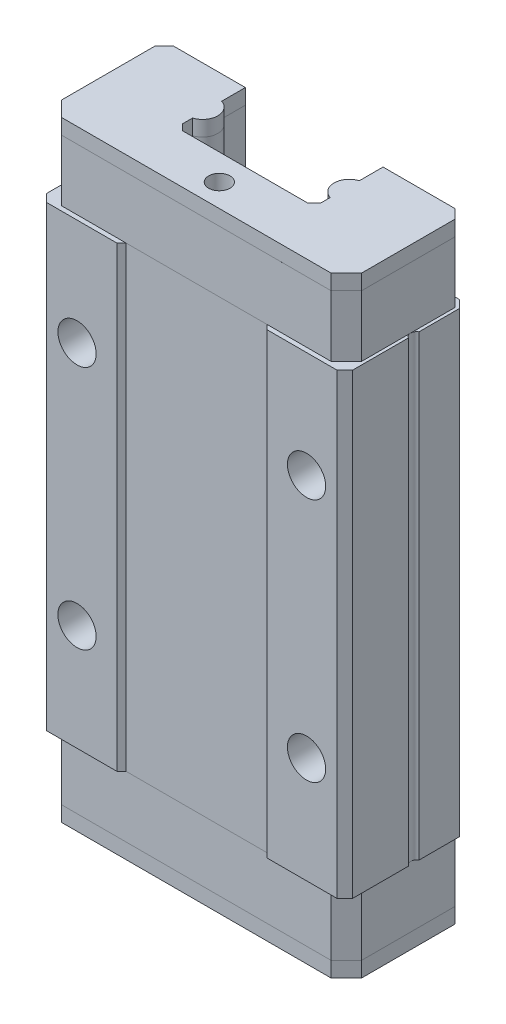
from build123d import *

# Parameters (mm, degrees)
SKICA1_W                 = 20
SKICA1_H                 = 29.9
P_IDAT_VYSUNUT_M1_DEPTH  = 8
ZKOSEN_1_SIZE            = 0.5
ODEBRAT_VYSUNUT_M1_DEPTH = 30.9
M3_Z_VIT1_D              = 2.5
M3_Z_VIT1_DEPTH          = 6
M3_Z_VIT1_TIP            = 0.751075774
P_IDAT_VYSUNUT_M2_DEPTH  = 4
P_IDAT_VYSUNUT_M3_DEPTH  = 1
LINPOLE1_COUNT           = 2
LINPOLE1_PITCH           = 33.9
LINPOLE2_COUNT           = 2
LINPOLE2_PITCH           = 38.9
ODEBRAT_VYSUNUT_M2_DEPTH = 40.9
ODEBRAT_VYSUNUT_M3_DEPTH = 35.9
SKICA9_R                 = 0.7
ODEBRAT_VYSUNUT_M4_DEPTH = 2


with BuildPart() as part:
    # Skica1 → Přidat vysunutím1 (new body)
    with BuildSketch(Plane.XY):
        Rectangle(SKICA1_W, SKICA1_H)
    extrude(amount=P_IDAT_VYSUNUT_M1_DEPTH)

    # Zkosení1
    zkosen_1_edges = [part.edges().sort_by_distance(p)[0] for p in [
        (-10, 0, 8),
        (10, 0, 8),
        (-10, 0, 0),
        (10, 0, 0),
    ]]
    chamfer(zkosen_1_edges, length=ZKOSEN_1_SIZE)

    # Skica2 → Odebrat vysunutím1 (cut, through all)
    with BuildSketch(Plane.XZ.offset(14.95)):
        Polygon((-4.9, 8), (4.9, 8), (4.6, 7.7), (-4.6, 7.7), align=None)
    extrude(amount=-ODEBRAT_VYSUNUT_M1_DEPTH, mode=Mode.SUBTRACT)

    # M3 závit1
    with Locations(Plane.XY.offset(8)):
        with Locations((-7.5, 8), (-7.5, -8), (7.5, -8), (7.5, 8)):
            Hole(M3_Z_VIT1_D / 2, depth=M3_Z_VIT1_DEPTH)
            with Locations((0, 0, -(M3_Z_VIT1_DEPTH + M3_Z_VIT1_TIP / 2))):  # 118° drill point
                Cone(0, M3_Z_VIT1_D / 2, M3_Z_VIT1_TIP, mode=Mode.SUBTRACT)


with BuildPart() as body_2:
    # Skica5 → Přidat vysunutím2 (new body)
    with BuildSketch(Plane.XZ.offset(14.95)):
        Polygon((-4.6, 7.7), (4.6, 7.7), (8.8, 7.7), (9.8, 6.7), (9.8, 0.6), (9.2, 0), (-9.2, 0), (-9.8, 0.6), (-9.8, 6.7), (-8.8, 7.7), align=None)
    p_idat_vysunut_m2 = extrude(amount=P_IDAT_VYSUNUT_M2_DEPTH)


with BuildPart() as body_3:
    # Skica6 → Přidat vysunutím3 (new body)
    with BuildSketch(Plane.XZ.offset(18.95)):
        Polygon((8.8, 7.7), (-8.8, 7.7), (-9.8, 6.7), (-9.8, 0.6), (-9.2, 0), (9.2, 0), (9.8, 0.6), (9.8, 6.7), align=None)
    extrude(amount=P_IDAT_VYSUNUT_M3_DEPTH)


with BuildPart() as linpole1_1:
    # LinPole1: Přidat vysunutím2 ×2
    with Locations(*[(0, i * LINPOLE1_PITCH, 0) for i in range(1, LINPOLE1_COUNT)]):
        add(p_idat_vysunut_m2)


with BuildPart() as linpole2_1:
    # LinPole2: pattern copy
    add(body_3.part.moved(Location(Vector(0, 1, 0) * (1 * LINPOLE2_PITCH))))


with BuildPart() as odebrat_vysunut_m2_tool:
    # Skica7 → Odebrat vysunutím2 (new body, through all)
    with BuildSketch(Plane.XZ.offset(19.95)):
        with BuildLine():
            Line((-4.5, 1.546060799), (-4.5, 0))
            Line((-4.5, 0), (4.5, 0))
            Line((4.5, 0), (4.5, 1.546060799))
            ThreePointArc((4.5, 1.546060799), (3.8, 2.5), (4.5, 3.453939201))
            Line((4.5, 3.453939201), (4.5, 4.1))
            Line((4.5, 4.1), (4.1, 4.5))
            Line((4.1, 4.5), (-4.1, 4.5))
            Line((-4.1, 4.5), (-4.5, 4.1))
            Line((-4.5, 4.1), (-4.5, 3.453939201))
            ThreePointArc((-4.5, 3.453939201), (-3.8, 2.5), (-4.5, 1.546060799))
        make_face()
    extrude(amount=-ODEBRAT_VYSUNUT_M2_DEPTH)


with BuildPart() as part_1:
    add(part.part)

    # Odebrat vysunutím2: cut by odebrat_vysunut_m2_tool
    add(odebrat_vysunut_m2_tool.part, mode=Mode.SUBTRACT)

    # Skica8 → Odebrat vysunutím3 (cut, through all)
    with BuildSketch(Plane.XZ.offset(14.95)):
        with BuildLine():
            Line((10, 3.846410162), (10, 3.153589838))
            ThreePointArc((10, 3.153589838), (9.8, 3.5), (10, 3.846410162))
        make_face()
    extrude(amount=-ODEBRAT_VYSUNUT_M3_DEPTH, mode=Mode.SUBTRACT)


with BuildPart() as body_2_1:
    add(body_2.part)

    # Odebrat vysunutím2: cut by odebrat_vysunut_m2_tool
    add(odebrat_vysunut_m2_tool.part, mode=Mode.SUBTRACT)


with BuildPart() as body_3_1:
    add(body_3.part)

    # Odebrat vysunutím2: cut by odebrat_vysunut_m2_tool
    add(odebrat_vysunut_m2_tool.part, mode=Mode.SUBTRACT)


with BuildPart() as linpole1_1_1:
    add(linpole1_1.part)

    # Odebrat vysunutím2: cut by odebrat_vysunut_m2_tool
    add(odebrat_vysunut_m2_tool.part, mode=Mode.SUBTRACT)


with BuildPart() as linpole2_1_1:
    add(linpole2_1.part)

    # Odebrat vysunutím2: cut by odebrat_vysunut_m2_tool
    add(odebrat_vysunut_m2_tool.part, mode=Mode.SUBTRACT)


with BuildPart() as odebrat_vysunut_m4_tool:
    # Skica9 → Odebrat vysunutím4 (new body)
    with BuildSketch(Plane(origin=(0, 19.95, 0), x_dir=(1, 0, 0), z_dir=(0, 1, 0))):
        with Locations((0, -6.2)):
            Circle(SKICA9_R)
    odebrat_vysunut_m4 = extrude(amount=-ODEBRAT_VYSUNUT_M4_DEPTH)


with BuildPart() as linpole1_1_2:
    add(linpole1_1_1.part)

    # Odebrat vysunutím4: cut by odebrat_vysunut_m4_tool
    add(odebrat_vysunut_m4_tool.part, mode=Mode.SUBTRACT)


with BuildPart() as linpole2_1_2:
    add(linpole2_1_1.part)

    # Odebrat vysunutím4: cut by odebrat_vysunut_m4_tool
    add(odebrat_vysunut_m4_tool.part, mode=Mode.SUBTRACT)


with BuildPart() as zrcadlit4_tool:
    # Zrcadlit4: Odebrat vysunutím4 across plane
    add(odebrat_vysunut_m4.mirror(Plane.ZX))


with BuildPart() as body_2_2:
    add(body_2_1.part)

    # Zrcadlit4: cut by zrcadlit4_tool
    add(zrcadlit4_tool.part, mode=Mode.SUBTRACT)


with BuildPart() as body_3_2:
    add(body_3_1.part)

    # Zrcadlit4: cut by zrcadlit4_tool
    add(zrcadlit4_tool.part, mode=Mode.SUBTRACT)


solid = Compound([part_1.part, linpole1_1_2.part, linpole2_1_2.part, body_2_2.part, body_3_2.part])
